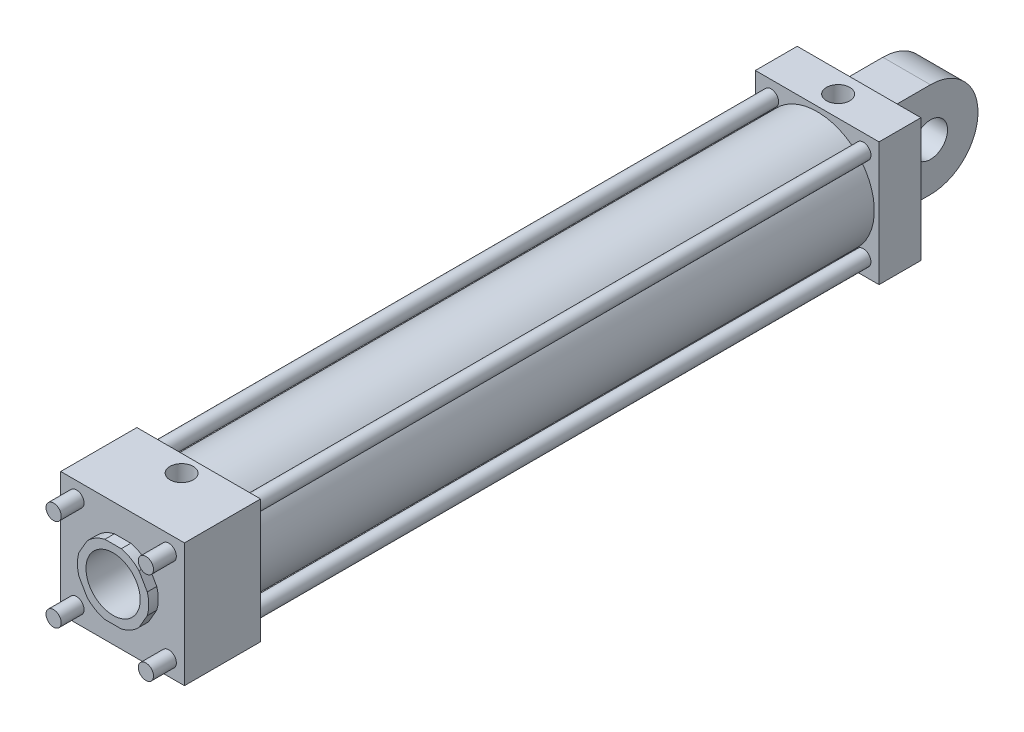
from build123d import *

# Parameters (mm, degrees)
ESBO_O1_W                = 130
ESBO_O1_H                = 130
RESSALTO_EXTRUS_O1_DEPTH = 44
ESBO_O13_R               = 45
ESBO_O13_R_2             = 40
RESSALTO_EXTRUS_O7_DEPTH = 10
ESBO_O2_R                = 60
ESBO_O2_R_2              = 50
RESSALTO_EXTRUS_O2_DEPTH = 650
ESBO_O3_W                = 130
ESBO_O3_H                = 130
RESSALTO_EXTRUS_O3_DEPTH = 80
ESBO_O4_R                = 8
RESSALTO_EXTRUS_O4_DEPTH = 754
ESBO_O5_R                = 37.5
RESSALTO_EXTRUS_O5_DEPTH = 10
CORTE_EXTRUS_O1_DEPTH    = 10
ESBO_O7_R                = 28.5
CORTE_EXTRUS_O2_DEPTH    = 280
ESBO_O8_W                = 50
ESBO_O8_H                = 100
RESSALTO_EXTRUS_O6_DEPTH = 100
ESBO_O9_R                = 18
CORTE_EXTRUS_O3_DEPTH    = 91
ESBO_O10_R               = 12.25
CORTE_EXTRUS_O4_DEPTH    = 65
ESBO_O11_R               = 12.25
CORTE_EXTRUS_O5_DEPTH    = 65
ESBO_O12_R               = 40
CORTE_EXTRUS_O6_DEPTH    = 22
ESBO_O14_R               = 45
ESBO_O14_R_2             = 40
RESSALTO_EXTRUS_O8_DEPTH = 10


with BuildPart() as part:
    # Esboço1 → Ressalto-extrusão1 (new body)
    with BuildSketch(Plane.XY):
        Rectangle(ESBO_O1_W, ESBO_O1_H)
    extrude(amount=RESSALTO_EXTRUS_O1_DEPTH)

    # Esboço13 → Ressalto-extrusão7 (add)
    with BuildSketch(Plane.XY.offset(44)):
        Circle(ESBO_O13_R)
        Circle(ESBO_O13_R_2, mode=Mode.SUBTRACT)
    extrude(amount=RESSALTO_EXTRUS_O7_DEPTH)

    # Esboço2 → Ressalto-extrusão2 (add)
    with BuildSketch(Plane.XY.offset(44)):
        Circle(ESBO_O2_R)
        Circle(ESBO_O2_R_2, mode=Mode.SUBTRACT)
    extrude(amount=RESSALTO_EXTRUS_O2_DEPTH)

    # Esboço3 → Ressalto-extrusão3 (add)
    with BuildSketch(Plane.XY.offset(694)):
        Rectangle(ESBO_O3_W, ESBO_O3_H)
    extrude(amount=RESSALTO_EXTRUS_O3_DEPTH)

    # Esboço4 → Ressalto-extrusão4 (add)
    with BuildSketch(Plane.XY.offset(44)):
        with Locations((-48.5, 48.5)):
            Circle(ESBO_O4_R)
        with Locations((-48.5, -48.5)):
            Circle(ESBO_O4_R)
        with Locations((48.5, -48.5)):
            Circle(ESBO_O4_R)
        with Locations((48.5, 48.5)):
            Circle(ESBO_O4_R)
    extrude(amount=RESSALTO_EXTRUS_O4_DEPTH)

    # Esboço5 → Ressalto-extrusão5 (add)
    with BuildSketch(Plane.XY.offset(774)):
        Circle(ESBO_O5_R)
    extrude(amount=RESSALTO_EXTRUS_O5_DEPTH)

    # Esboço6 → Corte-extrusão1 (cut)
    with BuildSketch(Plane.XY.offset(784)):
        with BuildLine():
            Line((-35.911089872, 10.800167787), (-27.308764605, 25.699832213))
            ThreePointArc((-27.308764605, 25.699832213), (-32.475952642, 18.75), (-35.911089872, 10.800167787))
        make_face()
        with BuildLine():
            Line((-8.602325267, 36.5), (8.602325267, 36.5))
            ThreePointArc((8.602325267, 36.5), (0, 37.5), (-8.602325267, 36.5))
        make_face()
        with BuildLine():
            Line((27.308764605, 25.699832213), (35.911089872, 10.800167787))
            ThreePointArc((35.911089872, 10.800167787), (32.475952642, 18.75), (27.308764605, 25.699832213))
        make_face()
        with BuildLine():
            ThreePointArc((-35.911089872, -10.800167787), (-32.475952642, -18.75), (-27.308764605, -25.699832213))
            Line((-27.308764605, -25.699832213), (-35.911089872, -10.800167787))
        make_face()
        with BuildLine():
            ThreePointArc((-8.602325267, -36.5), (0, -37.5), (8.602325267, -36.5))
            Line((8.602325267, -36.5), (-8.602325267, -36.5))
        make_face()
        with BuildLine():
            ThreePointArc((27.308764605, -25.699832213), (32.475952642, -18.75), (35.911089872, -10.800167787))
            Line((35.911089872, -10.800167787), (27.308764605, -25.699832213))
        make_face()
    extrude(amount=-CORTE_EXTRUS_O1_DEPTH, mode=Mode.SUBTRACT)

    # Esboço7 → Corte-extrusão2 (cut)
    with BuildSketch(Plane.XY.offset(784)):
        Circle(ESBO_O7_R)
    extrude(amount=-CORTE_EXTRUS_O2_DEPTH, mode=Mode.SUBTRACT)

    # Esboço8 → Ressalto-extrusão6 (add)
    with BuildSketch(Plane(origin=(0, 0, 0), x_dir=(-1, 0, 0), z_dir=(0, 0, -1))):
        Rectangle(ESBO_O8_W, ESBO_O8_H)
    extrude(amount=RESSALTO_EXTRUS_O6_DEPTH)

    # Esboço9 → Corte-extrusão3 (cut, through all)
    with BuildSketch(Plane.ZY.offset(25)):
        with BuildLine():
            Line((-100, 50), (-100, 2.01e-07))
            ThreePointArc((-100, 2.01e-07), (-85.355338988, 35.355339131), (-50, 50))
            Line((-50, 50), (-100, 50))
        make_face()
        with BuildLine():
            Line((-100, -50), (-50, -50))
            ThreePointArc((-50, -50), (-85.355339131, -35.355338988), (-100, 2.01e-07))
            Line((-100, 2.01e-07), (-100, -50))
        make_face()
        with Locations((-50, 0)):
            Circle(ESBO_O9_R)
    extrude(amount=-CORTE_EXTRUS_O3_DEPTH, mode=Mode.SUBTRACT)

    # Esboço10 → Corte-extrusão4 (cut)
    with BuildSketch(Plane(origin=(0, 65, 0), x_dir=(1, 0, 0), z_dir=(0, 1, 0))):
        with Locations((0, -22)):
            Circle(ESBO_O10_R)
    extrude(amount=-CORTE_EXTRUS_O4_DEPTH, mode=Mode.SUBTRACT)

    # Esboço11 → Corte-extrusão5 (cut)
    with BuildSketch(Plane(origin=(0, 65, 0), x_dir=(1, 0, 0), z_dir=(0, 1, 0))):
        with Locations((0, -712)):
            Circle(ESBO_O11_R)
    extrude(amount=-CORTE_EXTRUS_O5_DEPTH, mode=Mode.SUBTRACT)

    # Esboço12 → Corte-extrusão6 (cut)
    with BuildSketch(Plane.XY.offset(44)):
        Circle(ESBO_O12_R)
    extrude(amount=-CORTE_EXTRUS_O6_DEPTH, mode=Mode.SUBTRACT)

    # Esboço14 → Ressalto-extrusão8 (add)
    with BuildSketch(Plane(origin=(0, 0, 694), x_dir=(-1, 0, 0), z_dir=(0, 0, -1))):
        Circle(ESBO_O14_R)
        Circle(ESBO_O14_R_2, mode=Mode.SUBTRACT)
    extrude(amount=RESSALTO_EXTRUS_O8_DEPTH)


solid = part.part
